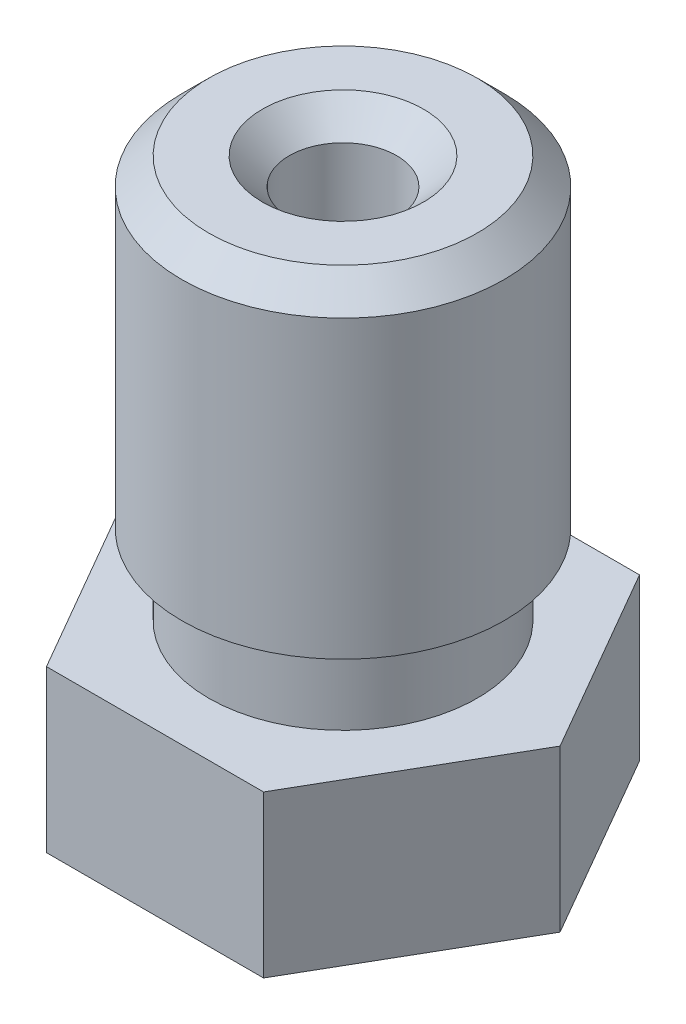
from build123d import *

# Parameters (mm, degrees)
BOSS_EXTRUDE1_DEPTH = 3
CHAMFER1_SIZE       = 0.5


with BuildPart() as part:
    # Sketch1 → Boss-Extrude1 (new body)
    with BuildSketch(Plane.XZ):
        Polygon((-2.020725942, 3.5), (-4.041451884, 0), (-2.020725942, -3.5), (2.020725942, -3.5), (4.041451884, 0), (2.020725942, 3.5), align=None)
    extrude(amount=-BOSS_EXTRUDE1_DEPTH)

    # Sketch2 → Revolve1 (revolve)
    with BuildSketch(Plane(origin=(0, 0, 0), x_dir=(-1, 0, 0), z_dir=(0, 0, -1))):
        Polygon((-2.5, 3), (0, 3), (0, 10.5), (-3, 10.5), (-3, 4.5), (-2.5, 4.5), align=None)
    revolve(axis=Axis((0, 3, 0), (0, 1, 0)))

    # Sketch3 → Revolve2 (revolve)
    with BuildSketch(Plane.XY):
        Polygon((2.5, 0), (0, 0), (0, -2), (0.5, -2), align=None)
    revolve(axis=Axis((0, 0, 0), (0, -1, 0)))

    # Sketch4 → Cut-Revolve1 (revolve, cut)
    with BuildSketch(Plane(origin=(0, 0, 0), x_dir=(-1, 0, 0), z_dir=(0, 0, -1))):
        Polygon((-0.2, -2), (0, -2), (0, 10.5), (-1, 10.5), (-1, 0), (-0.75, -0.227272727), (-0.75, -0.7), (-0.2, -1.2), align=None)
    revolve(axis=Axis((0, -2, 0), (0, 1, 0)), mode=Mode.SUBTRACT)

    # Chamfer1
    chamfer1_edges = [part.edges().sort_by_distance(p)[0] for p in [
        (-3, 10.5, 0),
        (-1, 10.5, 0),
    ]]
    chamfer(chamfer1_edges, length=CHAMFER1_SIZE)


solid = part.part
